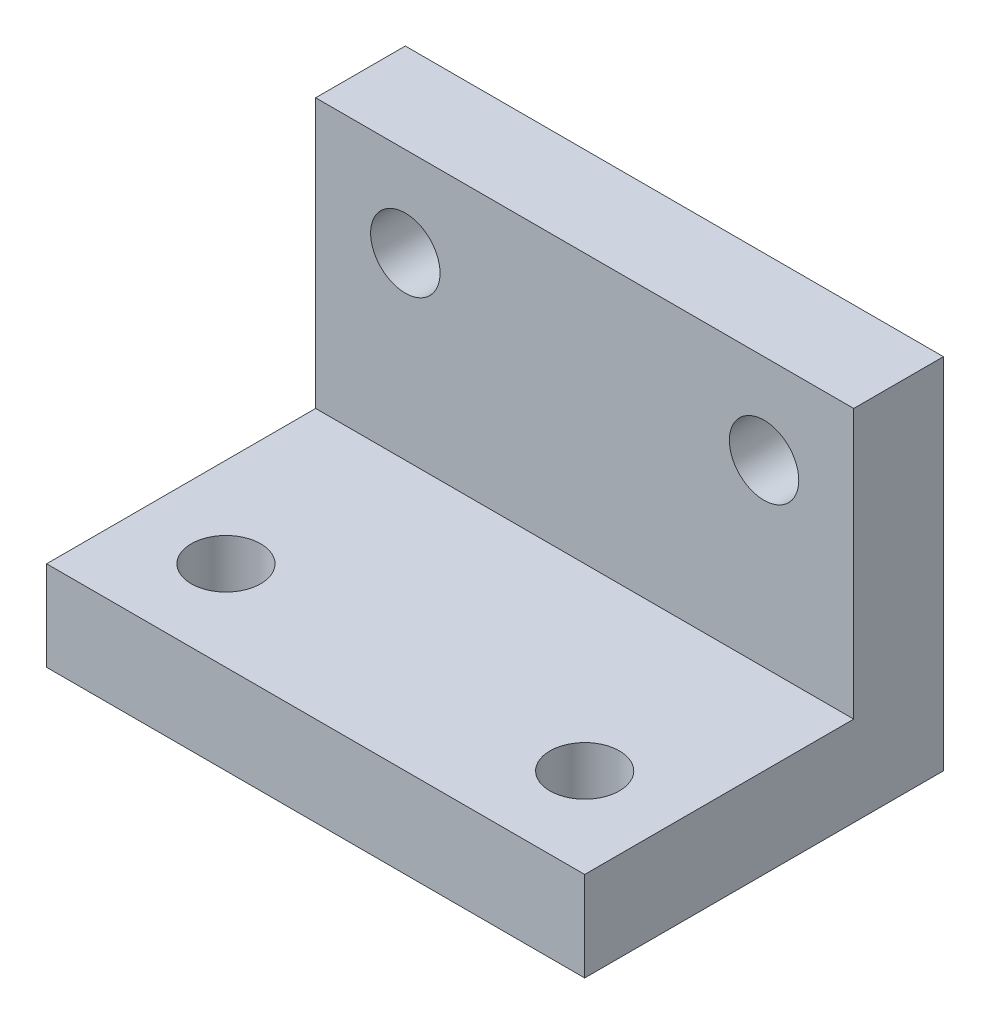
from build123d import *

# Parameters (mm, degrees)
SKETCH1_W                        = 38.1
SKETCH1_H                        = 25.4
BOSS_EXTRUDE1_DEPTH              = 12.7
CUT_EXTRUDE1_REACH               = 40.1
SKETCH2_W                        = 19.05
SKETCH2_H                        = 19.05
F_10_0_1935_DIAMETER_HOLE2_D     = 4.9149
F_10_0_1935_DIAMETER_HOLE2_DEPTH = 6.35
F_10_0_1935_DIAMETER_HOLE1_D     = 4.9149
F_10_0_1935_DIAMETER_HOLE1_DEPTH = 12.7
F_10_0_1935_DIAMETER_HOLE1_TIP   = 1.476584928


with BuildPart() as part:
    # Sketch1 → Boss-Extrude1 (new body, symmetric)
    with BuildSketch(Plane(origin=(0, 0, 0), x_dir=(1, 0, 0), z_dir=(0, 1, 0))):
        Rectangle(SKETCH1_W, SKETCH1_H)
    extrude(amount=BOSS_EXTRUDE1_DEPTH, both=True)

    # Sketch2 → Cut-Extrude1 (cut, up to next)
    with BuildSketch(Plane(origin=(19.05, 0, 0), x_dir=(0, 0, -1), z_dir=(1, 0, 0)), mode=Mode.PRIVATE) as cut_extrude1_sk1:
        with Locations((-3.175, 3.175)):
            Rectangle(SKETCH2_W, SKETCH2_H)
    cut_extrude1_tool1 = extrude(cut_extrude1_sk1.sketch, amount=-CUT_EXTRUDE1_REACH, mode=Mode.PRIVATE) & part.part
    add(cut_extrude1_tool1.solids().sort_by_distance((19.05, 3.175, 3.175))[0], mode=Mode.SUBTRACT)

    # #10 (0.1935) Diameter Hole2
    with Locations(Plane.XY.offset(-6.35)):
        with Locations((-12.7, 6.35), (12.7, 6.35)):
            Hole(F_10_0_1935_DIAMETER_HOLE2_D / 2, depth=F_10_0_1935_DIAMETER_HOLE2_DEPTH)

    # #10 (0.1935) Diameter Hole1
    with Locations(Plane(origin=(0, -6.35, 0), x_dir=(1, 0, 0), z_dir=(0, 1, 0))):
        with Locations((-12.7, -6.35), (12.7, -6.35)):
            Hole(F_10_0_1935_DIAMETER_HOLE1_D / 2, depth=F_10_0_1935_DIAMETER_HOLE1_DEPTH)
            with Locations((0, 0, -(F_10_0_1935_DIAMETER_HOLE1_DEPTH + F_10_0_1935_DIAMETER_HOLE1_TIP / 2))):  # 118° drill point
                Cone(0, F_10_0_1935_DIAMETER_HOLE1_D / 2, F_10_0_1935_DIAMETER_HOLE1_TIP, mode=Mode.SUBTRACT)


solid = part.part
